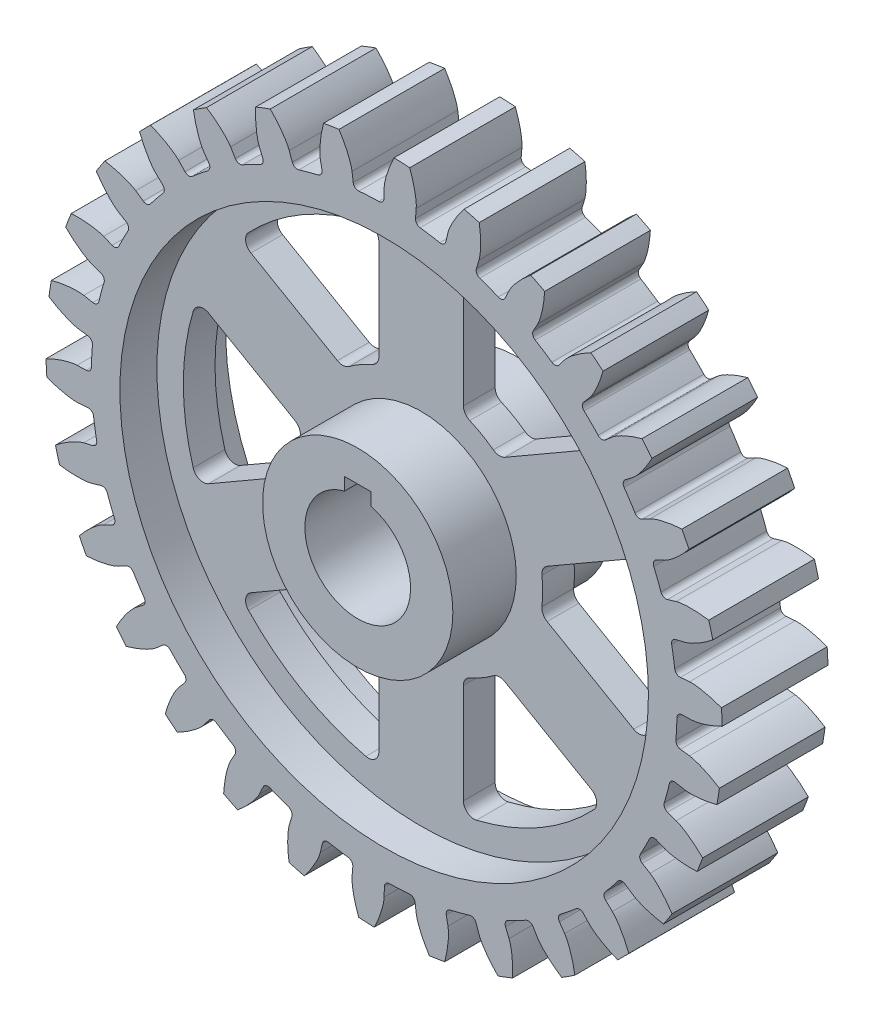
from build123d import *

# Parameters (mm, degrees)
BOSS_EXTRUDE2_DEPTH      = 12.7
FILLET5_R                = 1.27
FILLET6_R                = 1.27
CIRPATTERN1_COUNT        = 30
FILLET5_OF_CIRPATTERN1_R = 1.27
FILLET6_OF_CIRPATTERN1_R = 1.27
CUT_EXTRUDE1_DEPTH       = 20.05
CUT_EXTRUDE1_DEPTH_BACK  = 20.05
CUT_EXTRUDE2_DEPTH       = 20.05
FILLET7_R                = 2.54
CIRPATTERN2_COUNT        = 6
FILLET7_OF_CIRPATTERN2_R = 2.54


with BuildPart() as part:
    # Sketch1 → Revolve2 (revolve)
    with BuildSketch(Plane(origin=(0, 0, 0), x_dir=(0, 0, -1), z_dir=(1, 0, 0))):
        Polygon((-19.05, 0), (19.05, 0), (19.05, 22.86), (3.81, 22.86), (3.81, 63.5), (12.7, 63.5), (12.7, 70.358), (-12.7, 70.358), (-12.7, 63.5), (-3.81, 63.5), (-3.81, 22.86), (-19.05, 22.86), align=None)
    revolve(axis=Axis((0, 0, 20.955), (0, 0, -1)))

    # Sketch2 → Boss-Extrude2 (add, symmetric)
    with BuildSketch(Plane.XY):
        with BuildLine():
            Line((73.787007634, -0.000360765), (70.357962208, -0.072923753))
            ThreePointArc((70.357962208, -0.072923753), (70.261576806, 3.682253209), (69.964911322, 7.426933937))
            Line((69.964911322, 7.426933937), (73.382787093, 7.712841719))
            add(Edge.make_bspline(
                [(73.382787093, 7.712841719), (73.43715987, 7.717395802), (73.589918341, 7.726601957), (73.879547725, 7.729925227), (74.35231969, 7.715277138), (74.954131213, 7.6672137), (75.72992196, 7.571305619), (76.639687317, 7.415196261), (77.633599645, 7.19844931), (78.70649498, 6.91461528), (79.695065382, 6.611264762), (80.410512864, 6.366046257), (80.860156706, 6.202224664), (81.04836389, 6.131974458)],
                knots=[0, 0, 0, 0, 0, 0.005376748, 0.015083688, 0.02853182, 0.046610139, 0.064854849, 0.092110525, 0.119476175, 0.146842495, 0.174208853, 0.194009379, 0.194009379, 0.194009379, 0.194009379, 0.194009379], degree=4))
            ThreePointArc((81.04836389, 6.131974458), (81.168617992, 4.253687023), (81.245348836, 2.373118728))
            add(Edge.make_bspline(
                [(73.787007634, -0.000360765), (73.841558582, 0.000793603), (73.994442531, 0.007605488), (74.282832671, 0.034574938), (74.751483601, 0.09856091), (75.34497434, 0.209267485), (76.106490099, 0.385742386), (76.994953796, 0.636092935), (77.960765142, 0.955544652), (78.998114309, 1.349971911), (79.949561191, 1.754994701), (80.635457778, 2.07365486), (81.065515109, 2.283579978), (81.245348836, 2.373118728)],
                knots=[0, 0, 0, 0, 0, 0.005376748, 0.015083688, 0.02853182, 0.046610139, 0.064854849, 0.092110525, 0.119476175, 0.146842495, 0.174208853, 0.194009458, 0.194009458, 0.194009458, 0.194009458, 0.194009458], degree=4))
        make_face()
    boss_extrude2 = extrude(amount=BOSS_EXTRUDE2_DEPTH, both=True)

    # Fillet5
    fillet5_edges = [part.edges().sort_by_distance(p)[0] for p in [
        (69.964911322, 7.426933937, 0),
    ]]
    fillet(fillet5_edges, radius=FILLET5_R)

    # Fillet6
    fillet6_edges = [part.edges().sort_by_distance(p)[0] for p in [
        (70.357962208, -0.072923753, 0),
    ]]
    fillet(fillet6_edges, radius=FILLET6_R)

    # CirPattern1: Boss-Extrude2 ×30 about axis
    cirpattern1_axis = Axis((0, 0, 20.955), (0, 0, -1))
    for i in range(1, CIRPATTERN1_COUNT):
        add(boss_extrude2.rotate(cirpattern1_axis, i * 360 / CIRPATTERN1_COUNT))

    # Fillet5 of CirPattern1
    fillet5_of_cirpattern1_edges = [part.edges().sort_by_distance(p)[0] for p in [
        (69.980156538, -7.281885399, 0),
        (66.936933111, -21.672451401, 0),
        (60.968244508, -35.115827282, 0),
        (52.334951061, -47.024473005, 0),
        (41.414369123, -56.87792361, 0),
        (28.683780526, -64.245536022, 0),
        (14.699573079, -68.805310226, 0),
        (0.072923753, -70.357962208, 0),
        (-14.556912691, -68.835633628, 0),
        (-28.550542199, -64.304857547, 0),
        (-41.296376012, -56.963650623, 0),
        (-52.237360031, -47.132858824, 0),
        (-60.895320755, -35.242134927, 0),
        (-66.891863753, -21.811160623, 0),
        (-69.964911322, -7.426933937, 0),
        (-69.980156538, 7.281885399, 0),
        (-66.936933111, 21.672451401, 0),
        (-60.968244508, 35.115827282, 0),
        (-52.334951061, 47.024473005, 0),
        (-41.414369123, 56.87792361, 0),
        (-28.683780526, 64.245536022, 0),
        (-14.699573079, 68.805310226, 0),
        (-0.072923753, 70.357962208, 0),
        (14.556912691, 68.835633628, 0),
        (28.550542199, 64.304857547, 0),
        (41.296376012, 56.963650623, 0),
        (52.237360031, 47.132858824, 0),
        (60.895320755, 35.242134927, 0),
        (66.891863753, 21.811160623, 0),
    ]]
    fillet(fillet5_of_cirpattern1_edges, radius=FILLET5_OF_CIRPATTERN1_R)

    # Fillet6 of CirPattern1
    fillet6_of_cirpattern1_edges = [part.edges().sort_by_distance(p)[0] for p in [
        (68.805310226, -14.699573079, 0),
        (64.245536022, -28.683780526, 0),
        (56.87792361, -41.414369123, 0),
        (47.024473005, -52.334951061, 0),
        (35.115827282, -60.968244508, 0),
        (21.672451401, -66.936933111, 0),
        (7.281885399, -69.980156538, 0),
        (-7.426933937, -69.964911322, 0),
        (-21.811160623, -66.891863753, 0),
        (-35.242134927, -60.895320755, 0),
        (-47.132858824, -52.237360031, 0),
        (-56.963650623, -41.296376012, 0),
        (-64.304857547, -28.550542199, 0),
        (-68.835633628, -14.556912691, 0),
        (-70.357962208, 0.072923753, 0),
        (-68.805310226, 14.699573079, 0),
        (-64.245536022, 28.683780526, 0),
        (-56.87792361, 41.414369123, 0),
        (-47.024473005, 52.334951061, 0),
        (-35.115827282, 60.968244508, 0),
        (-21.672451401, 66.936933111, 0),
        (-7.281885399, 69.980156538, 0),
        (7.426933937, 69.964911322, 0),
        (21.811160623, 66.891863753, 0),
        (35.242134927, 60.895320755, 0),
        (47.132858824, 52.237360031, 0),
        (56.963650623, 41.296376012, 0),
        (64.304857547, 28.550542199, 0),
        (68.835633628, 14.556912691, 0),
    ]]
    fillet(fillet6_of_cirpattern1_edges, radius=FILLET6_OF_CIRPATTERN1_R)

    # Sketch3 → Cut-Extrude1 (cut, two sides)
    with BuildSketch(Plane.XY) as cut_extrude1_sk:
        with BuildLine():
            Line((-3.175, 12.296722124), (-3.175, 15.344722124))
            Line((-3.175, 15.344722124), (3.175, 15.344722124))
            Line((3.175, 15.344722124), (3.175, 12.296722124))
            ThreePointArc((3.175, 12.296722124), (0, -12.7), (-3.175, 12.296722124))
        make_face()
    extrude(amount=CUT_EXTRUDE1_DEPTH, mode=Mode.SUBTRACT)
    extrude(cut_extrude1_sk.sketch, amount=-CUT_EXTRUDE1_DEPTH_BACK, mode=Mode.SUBTRACT)

    # Sketch4 → Cut-Extrude2 (cut, symmetric)
    with BuildSketch(Plane.XY):
        with BuildLine():
            Line((10.16, 27.386100489), (10.16, 56.239638157))
            ThreePointArc((10.16, 56.239638157), (28.575, 49.493351826), (43.624955343, 36.918637181))
            Line((43.624955343, 36.918637181), (18.637058734, 22.491868347))
            ThreePointArc((18.637058734, 22.491868347), (14.605, 25.296602045), (10.16, 27.386100489))
        make_face()
    cut_extrude2 = extrude(amount=CUT_EXTRUDE2_DEPTH, both=True, mode=Mode.SUBTRACT)

    # Fillet7
    fillet7_edges = [part.edges().sort_by_distance(p)[0] for p in [
        (18.637058734, 22.491868347, 0),
        (10.16, 27.386100489, 0),
        (10.16, 56.239638157, 0),
        (43.624955343, 36.918637181, 0),
    ]]
    fillet(fillet7_edges, radius=FILLET7_R)

    # CirPattern2: Cut-Extrude2 ×6 about axis
    cirpattern2_axis = Axis((0, 0, 0), (0, 0, 1))
    for i in range(1, CIRPATTERN2_COUNT):
        add(cut_extrude2.rotate(cirpattern2_axis, i * 360 / CIRPATTERN2_COUNT), mode=Mode.SUBTRACT)

    # Fillet7 of CirPattern2
    fillet7_of_cirpattern2_edges = [part.edges().sort_by_distance(p)[0] for p in [
        (-10.16, 27.386100489, 0),
        (-18.637058734, 22.491868347, 0),
        (-43.624955343, 36.918637181, 0),
        (-10.16, 56.239638157, 0),
        (-28.797058734, 4.894232142, 0),
        (-28.797058734, -4.894232142, 0),
        (-53.784955343, -19.321000976, 0),
        (-53.784955343, 19.321000976, 0),
        (-18.637058734, -22.491868347, 0),
        (-10.16, -27.386100489, 0),
        (-10.16, -56.239638157, 0),
        (-43.624955343, -36.918637181, 0),
        (10.16, -27.386100489, 0),
        (18.637058734, -22.491868347, 0),
        (43.624955343, -36.918637181, 0),
        (10.16, -56.239638157, 0),
        (28.797058734, -4.894232142, 0),
        (28.797058734, 4.894232142, 0),
        (53.784955343, 19.321000976, 0),
        (53.784955343, -19.321000976, 0),
    ]]
    fillet(fillet7_of_cirpattern2_edges, radius=FILLET7_OF_CIRPATTERN2_R)


solid = part.part
